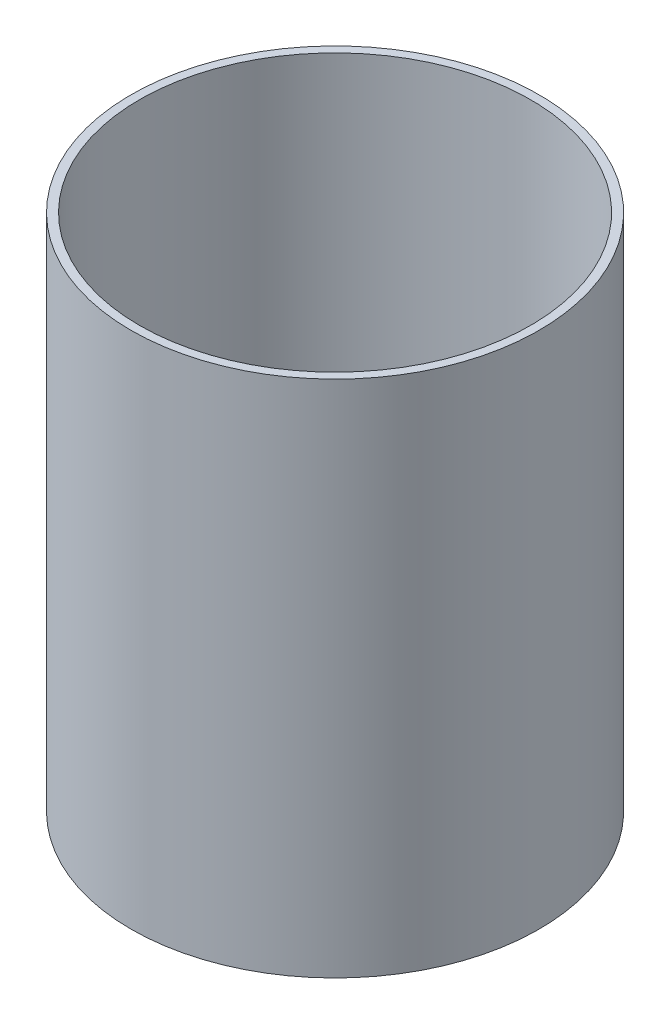
from build123d import *

# Parameters (mm, degrees)
SKETCH1_R           = 76.2
SKETCH1_R_2         = 73.025
BOSS_EXTRUDE1_DEPTH = 193.675


with BuildPart() as part:
    # Sketch1 → Boss-Extrude1 (new body)
    with BuildSketch(Plane(origin=(0, 0, 0), x_dir=(1, 0, 0), z_dir=(0, 1, 0))):
        Circle(SKETCH1_R)
        Circle(SKETCH1_R_2, mode=Mode.SUBTRACT)
    extrude(amount=BOSS_EXTRUDE1_DEPTH)


solid = part.part
